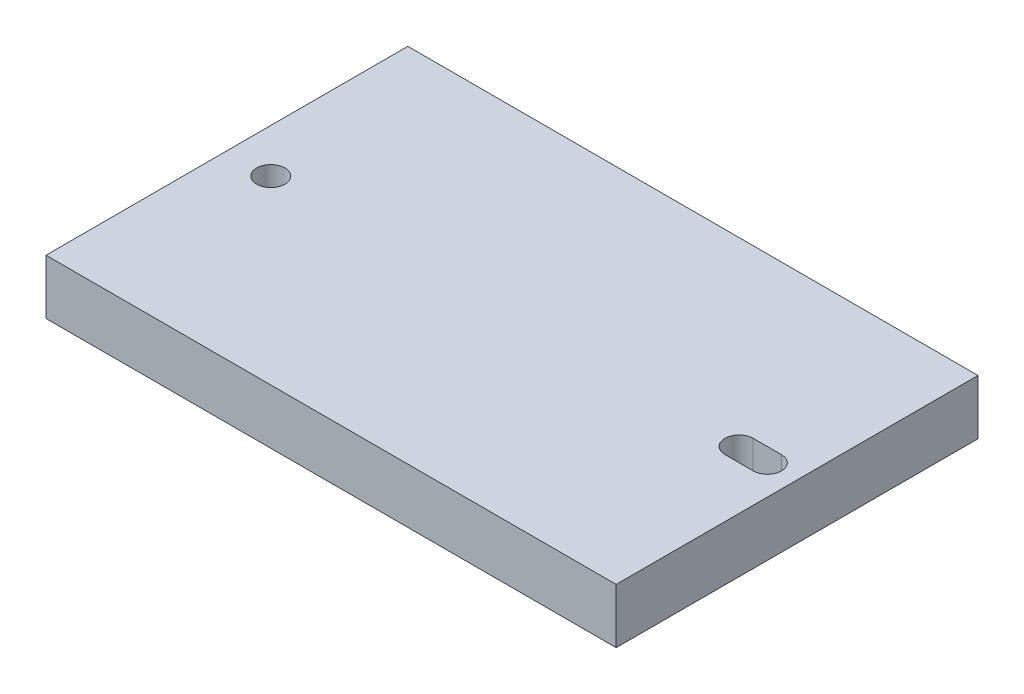
from build123d import *

# Parameters (mm, degrees)
SKETCH1_W                 = 66.04
SKETCH1_H                 = 41.91
BOSS_EXTRUDE1_DEPTH       = 6.35
F_5_CLEARANCE_HOLE1_D     = 3.2639
F_5_CLEARANCE_HOLE1_DEPTH = 12.7
F_5_CLEARANCE_HOLE1_TIP   = 0.980574487
CUT_EXTRUDE1_REACH        = 8.35


with BuildPart() as part:
    # Sketch1 → Boss-Extrude1 (new body)
    with BuildSketch(Plane(origin=(0, 0, 0), x_dir=(1, 0, 0), z_dir=(0, 1, 0))):
        with Locations((-9.748619051, 1.300163759)):
            Rectangle(SKETCH1_W, SKETCH1_H)
    extrude(amount=BOSS_EXTRUDE1_DEPTH)

    # #5 Clearance Hole1
    with Locations(Plane(origin=(0, 6.35, 0), x_dir=(-1, 0, 0), z_dir=(0, 1, 0))):
        with Locations((37.688619051, -1.300163759)):
            Hole(F_5_CLEARANCE_HOLE1_D / 2, depth=F_5_CLEARANCE_HOLE1_DEPTH)
            with Locations((0, 0, -(F_5_CLEARANCE_HOLE1_DEPTH + F_5_CLEARANCE_HOLE1_TIP / 2))):  # 118° drill point
                Cone(0, F_5_CLEARANCE_HOLE1_D / 2, F_5_CLEARANCE_HOLE1_TIP, mode=Mode.SUBTRACT)

    # Sketch13 → Cut-Extrude1 (cut, up to next)
    with BuildSketch(Plane(origin=(0, 6.35, 0), x_dir=(1, 0, 0), z_dir=(0, 1, 0)), mode=Mode.PRIVATE) as cut_extrude1_sk1:
        with BuildLine():
            Line((19.829680949, -0.331786241), (16.553080949, -0.331786241))
            ThreePointArc((16.553080949, -0.331786241), (14.921130949, 1.300163759), (16.553080949, 2.932113759))
            Line((16.553080949, 2.932113759), (19.829680949, 2.932113759))
            ThreePointArc((19.829680949, 2.932113759), (21.461630949, 1.300163759), (19.829680949, -0.331786241))
        make_face()
    cut_extrude1_tool1 = extrude(cut_extrude1_sk1.sketch, amount=-CUT_EXTRUDE1_REACH, mode=Mode.PRIVATE) & part.part
    add(cut_extrude1_tool1.solids().sort_by_distance((18.191381, 6.35, -1.300164))[0], mode=Mode.SUBTRACT)


solid = part.part
